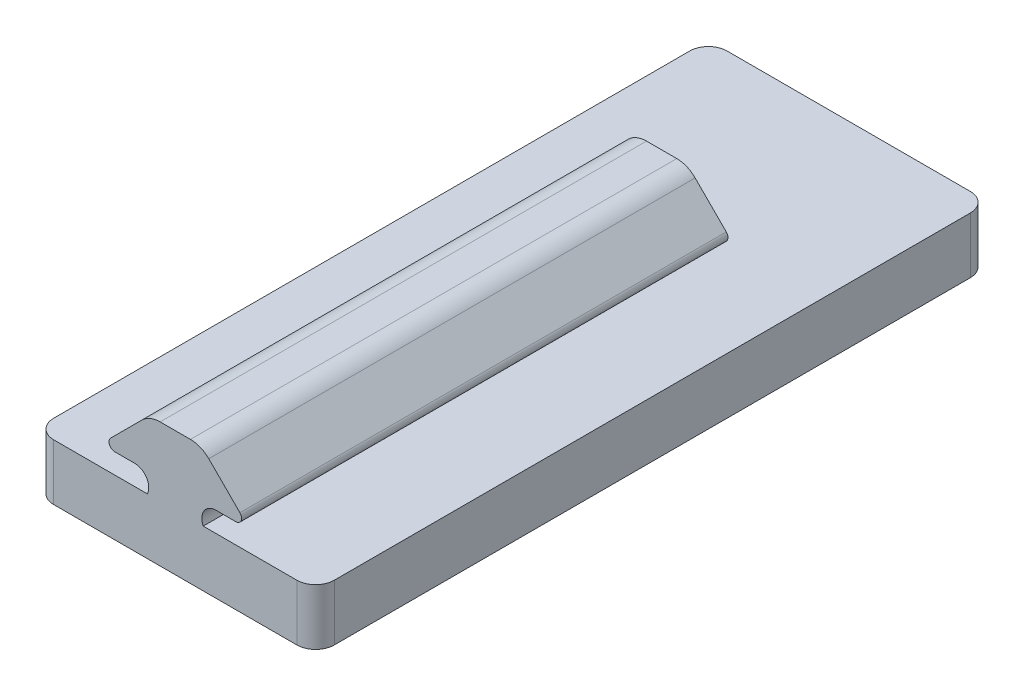
from build123d import *

# Parameters (mm, degrees)
BOSS_EXTRUDE1_DEPTH      = 6
SKETCH2_R                = 4
CUT_EXTRUDE1_DEPTH       = 2
SKETCH3_W                = 6
SKETCH3_H                = 1.2
BOSS_EXTRUDE2_DEPTH      = 36
BOSS_EXTRUDE2_DEPTH_BACK = 16


with BuildPart() as part:
    # Sketch1 → Boss-Extrude1 (new body)
    with BuildSketch(Plane(origin=(0, 0, 0), x_dir=(1, 0, 0), z_dir=(0, 1, 0))):
        with BuildLine():
            Line((-13, 36), (13, 36))
            ThreePointArc((13, 36), (14.414213562, 35.414213562), (15, 34))
            Line((15, 34), (15, -34))
            ThreePointArc((15, -34), (14.414213562, -35.414213562), (13, -36))
            Line((13, -36), (-13, -36))
            ThreePointArc((-13, -36), (-14.414213562, -35.414213562), (-15, -34))
            Line((-15, -34), (-15, 34))
            ThreePointArc((-15, 34), (-14.414213562, 35.414213562), (-13, 36))
        make_face()
    extrude(amount=BOSS_EXTRUDE1_DEPTH)

    # Sketch2 → Cut-Extrude1 (cut)
    with BuildSketch(Plane(origin=(0, 0, 0), x_dir=(1, 0, 0), z_dir=(0, 1, 0))):
        with Locations((0, 24)):
            Circle(SKETCH2_R)
        with Locations((0, -24)):
            Circle(SKETCH2_R)
    extrude(amount=CUT_EXTRUDE1_DEPTH, mode=Mode.SUBTRACT)

    # Sketch3 → Boss-Extrude2 (add, two sides)
    with BuildSketch(Plane.XY) as boss_extrude2_sk:
        with BuildLine():
            Line((-4.343002999, 5.144651552), (-4.916686599, 5.144651552))
            Line((-4.916686599, 5.144651552), (-4.916686599, 3.944651552))
            Line((-4.916686599, 3.944651552), (4.917480601, 3.944651552))
            Line((4.917480601, 3.944651552), (4.917480601, 5.144651552))
            Line((4.917480601, 5.144651552), (4.343796972, 5.144651552))
            ThreePointArc((4.343796972, 5.144651552), (2.838896972, 6.649551552), (4.343796972, 8.154451552))
            Line((4.343796972, 8.154451552), (6.475191456, 8.154451552))
            ThreePointArc((6.475191456, 8.154451552), (7.044301248, 8.534718558), (6.910769234, 9.206029329))
            Line((6.910769234, 9.206029329), (3.580725693, 12.53607287))
            ThreePointArc((3.580725693, 12.53607287), (2.6804509, 13.137617255), (1.618504375, 13.348851552))
            Line((1.618504375, 13.348851552), (-1.617710374, 13.348851552))
            ThreePointArc((-1.617710374, 13.348851552), (-2.679656898, 13.137617255), (-3.579931691, 12.53607287))
            Line((-3.579931691, 12.53607287), (-6.909975232, 9.206029329))
            ThreePointArc((-6.909975232, 9.206029329), (-7.043507247, 8.534718558), (-6.474397455, 8.154451552))
            Line((-6.474397455, 8.154451552), (-4.343002999, 8.154451552))
            ThreePointArc((-4.343002999, 8.154451552), (-2.838102999, 6.649551552), (-4.343002999, 5.144651552))
        make_face()
        with Locations((-7.916686599, 4.544651552)):
            Rectangle(SKETCH3_W, SKETCH3_H)
        with Locations((7.917480601, 4.544651552)):
            Rectangle(SKETCH3_W, SKETCH3_H)
    extrude(amount=BOSS_EXTRUDE2_DEPTH)
    extrude(boss_extrude2_sk.sketch, amount=-BOSS_EXTRUDE2_DEPTH_BACK)


solid = part.part
